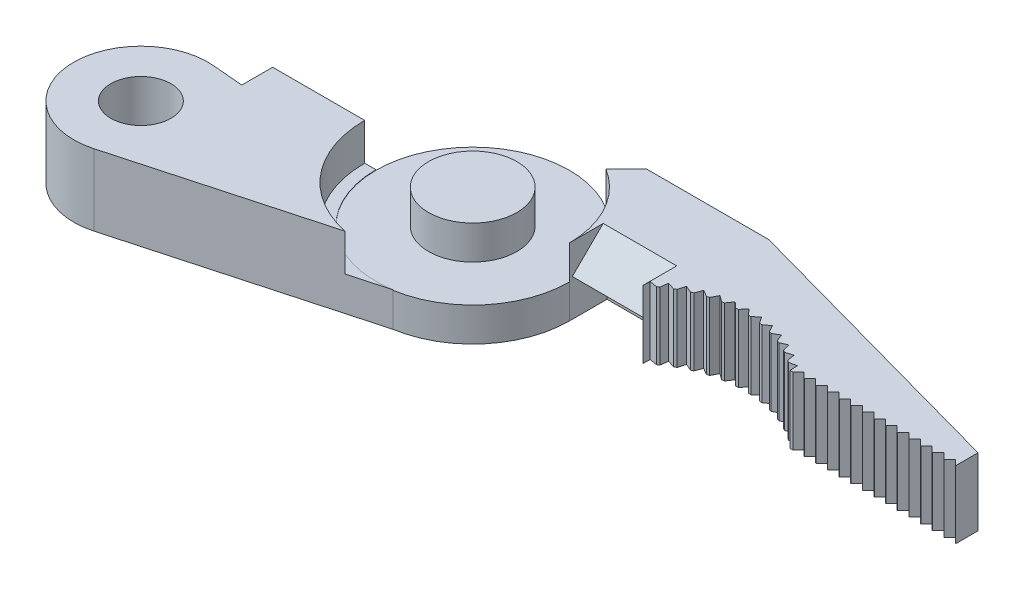
from build123d import *

# Parameters (mm, degrees)
SKETCH1_R                        = 6.5405
SKETCH1_R_2                      = 2.9845
BOSS_EXTRUDE1_DEPTH              = 4.826
SKETCH2_R                        = 2.032
BOSS_EXTRUDE2_DEPTH              = 4.826
F_42_0_0935_DIAMETER_HOLE1_D     = 2.3749
F_42_0_0935_DIAMETER_HOLE1_DEPTH = 2.032
F_42_0_0935_DIAMETER_HOLE1_TIP   = 0.713491942
BOSS_EXTRUDE3_DEPTH              = 4.826
CUT_EXTRUDE1_DEPTH               = 2.50825
CUT_EXTRUDE2_DEPTH               = 5.826
LPATTERN1_COUNT                  = 14
LPATTERN1_PITCH                  = 0.7874
CUT_EXTRUDE3_DEPTH               = 5.826
CIRPATTERN1_COUNT                = 13
CIRPATTERN1_ANGLE                = 76.5
SKETCH13_W                       = 4.971607039
SKETCH13_H                       = 2.54
CUT_EXTRUDE5_DEPTH               = 2.50825
BOSS_EXTRUDE4_REACH              = 28.099
SKETCH15_W                       = 4.971607039
SKETCH15_H                       = 2.54
CUT_EXTRUDE6_DEPTH               = 2.50825
SKETCH16_R                       = 6.5405
CUT_EXTRUDE7_DEPTH               = 2.54
SKETCH18_R                       = 2.9845
BOSS_EXTRUDE5_DEPTH              = 4.572
CUT_EXTRUDE8_DEPTH               = 0.254
CUT_EXTRUDE9_REACH               = 34.057


with BuildPart() as part:
    # Sketch1 → Boss-Extrude1 (new body)
    with BuildSketch(Plane(origin=(0, 0, 0), x_dir=(1, 0, 0), z_dir=(0, 1, 0))):
        Circle(SKETCH1_R)
        Circle(SKETCH1_R_2, mode=Mode.SUBTRACT)
    extrude(amount=BOSS_EXTRUDE1_DEPTH)

    # Sketch2 → Boss-Extrude2 (add)
    with BuildSketch(Plane(origin=(0, 0, 0), x_dir=(1, 0, 0), z_dir=(0, 1, 0))):
        with BuildLine():
            Line((-6.5405, 0), (-13.5255, 0))
            Line((-13.5255, 0), (-13.5255, -2.088510966))
            Line((-13.5255, -2.088510966), (-15.606063552, -1.906485242))
            ThreePointArc((-15.606063552, -1.906485242), (-20.526278057, -6.842542927), (-14.798031619, -10.81247605))
            Line((-14.798031619, -10.81247605), (1.058408056, -6.454294124))
            ThreePointArc((1.058408056, -6.454294124), (-4.234124606, -4.985010438), (-6.5405, 0))
        make_face()
        with Locations((-16.002, -6.432059555)):
            Circle(SKETCH2_R, mode=Mode.SUBTRACT)
    extrude(amount=BOSS_EXTRUDE2_DEPTH)

    # #42 (0.0935) Diameter Hole1
    with Locations(Plane(origin=(0, 0, 0), x_dir=(-1, 0, 0), z_dir=(0, 0, -1))):
        with Locations((10.033, 2.413)):
            Hole(F_42_0_0935_DIAMETER_HOLE1_D / 2, depth=F_42_0_0935_DIAMETER_HOLE1_DEPTH)
            with Locations((0, 0, -(F_42_0_0935_DIAMETER_HOLE1_DEPTH + F_42_0_0935_DIAMETER_HOLE1_TIP / 2))):  # 118° drill point
                Cone(0, F_42_0_0935_DIAMETER_HOLE1_D / 2, F_42_0_0935_DIAMETER_HOLE1_TIP, mode=Mode.SUBTRACT)

    # Sketch8 → Boss-Extrude3 (add)
    with BuildSketch(Plane(origin=(0, 0, 0), x_dir=(1, 0, 0), z_dir=(0, 1, 0))):
        with BuildLine():
            Line((13.081, 6.9342), (32.639, 1.524))
            Line((32.639, 1.524), (32.639, 0))
            Line((32.639, 0), (21.463, 0))
            ThreePointArc((21.463, 0), (16.51, 1.829301337), (11.557, 0))
            Line((11.557, 0), (6.5405, 0))
            ThreePointArc((6.5405, 0), (5.709882431, 3.189887596), (3.429, 5.569569036))
            Line((3.429, 5.569569036), (4.793630964, 6.9342))
            Line((4.793630964, 6.9342), (13.081, 6.9342))
        make_face()
    extrude(amount=BOSS_EXTRUDE3_DEPTH)

    # Sketch9 → Cut-Extrude1 (cut)
    with BuildSketch(Plane(origin=(0, 4.826, 0), x_dir=(1, 0, 0), z_dir=(0, 1, 0))):
        with BuildLine():
            Line((-6.5405, 0), (-7.3025, 0))
            ThreePointArc((-7.3025, 0), (-5.662092509, -4.611639044), (-1.477860583, -7.151393874))
            Line((-1.477860583, -7.151393874), (1.058408056, -6.454294124))
            ThreePointArc((1.058408056, -6.454294124), (-4.234124606, -4.985010438), (-6.5405, 0))
        make_face()
    extrude(amount=-CUT_EXTRUDE1_DEPTH, mode=Mode.SUBTRACT)

    # Sketch10 → Cut-Extrude2 (cut, through all)
    with BuildSketch(Plane(origin=(0, 4.826, 0), x_dir=(1, 0, 0), z_dir=(0, 1, 0))):
        Polygon((32.639, 0), (32.258, 0.381), (31.877, 0), align=None)
    cut_extrude2 = extrude(amount=-CUT_EXTRUDE2_DEPTH, mode=Mode.SUBTRACT)

    # LPattern1: Cut-Extrude2 ×14
    with Locations(*[(-i * LPATTERN1_PITCH, 0, 0) for i in range(1, LPATTERN1_COUNT)]):
        add(cut_extrude2, mode=Mode.SUBTRACT)

    # Sketch11 → Cut-Extrude3 (cut, through all)
    with BuildSketch(Plane(origin=(0, 4.826, 0), x_dir=(1, 0, 0), z_dir=(0, 1, 0))):
        with BuildLine():
            Line((21.463, 0), (21.438001029, 0.512539145))
            Line((21.438001029, 0.512539145), (20.934572554, 0.413135452))
            ThreePointArc((20.934572554, 0.413135452), (21.203334313, 0.212384964), (21.463, 0))
        make_face()
    cut_extrude3 = extrude(amount=-CUT_EXTRUDE3_DEPTH, mode=Mode.SUBTRACT)

    # CirPattern1: Cut-Extrude3 ×13 about axis
    cirpattern1_axis = Axis((16.51, 0, 5.790698663), (0, 1, 0))
    for i in range(1, CIRPATTERN1_COUNT):
        add(cut_extrude3.rotate(cirpattern1_axis, i * CIRPATTERN1_ANGLE / (CIRPATTERN1_COUNT - 1)), mode=Mode.SUBTRACT)

    # Sketch13 → Cut-Extrude5 (cut)
    with BuildSketch(Plane(origin=(0, 4.826, 0), x_dir=(1, 0, 0), z_dir=(0, 1, 0))):
        with Locations((9.02630352, 1.27)):
            Rectangle(SKETCH13_W, SKETCH13_H)
    extrude(amount=-CUT_EXTRUDE5_DEPTH, mode=Mode.SUBTRACT)

    # Sketch14 → Boss-Extrude4 (add, up to next)
    with BuildSketch(Plane(origin=(6.5405, 0, 0), x_dir=(0, 0, -1), z_dir=(1, 0, 0)), mode=Mode.PRIVATE) as boss_extrude4_sk1:
        Polygon((0, 2.31775), (2.54, 4.826), (2.54, 2.31775), align=None)
    boss_extrude4_tool1 = extrude(boss_extrude4_sk1.sketch, amount=BOSS_EXTRUDE4_REACH, mode=Mode.PRIVATE) - part.part
    add(boss_extrude4_tool1.solids().sort_by_distance((6.5405, 3.153833, -1.693333))[0])

    # Sketch15 → Cut-Extrude6 (cut)
    with BuildSketch(Plane.XZ):
        with Locations((9.02630352, -1.27)):
            Rectangle(SKETCH15_W, SKETCH15_H)
    extrude(amount=-CUT_EXTRUDE6_DEPTH, mode=Mode.SUBTRACT)

    # Sketch16 → Cut-Extrude7 (cut)
    with BuildSketch(Plane(origin=(0, 4.826, 0), x_dir=(1, 0, 0), z_dir=(0, 1, 0))):
        Circle(SKETCH16_R)
    extrude(amount=-CUT_EXTRUDE7_DEPTH, mode=Mode.SUBTRACT)

    # Sketch18 → Boss-Extrude5 (add)
    with BuildSketch(Plane(origin=(0, 0, 0), x_dir=(1, 0, 0), z_dir=(0, 1, 0))):
        Circle(SKETCH18_R)
    extrude(amount=BOSS_EXTRUDE5_DEPTH)

    # Sketch19 → Cut-Extrude8 (cut)
    with BuildSketch(Plane(origin=(0, 4.826, 0), x_dir=(1, 0, 0), z_dir=(0, 1, 0))):
        with BuildLine():
            Line((6.5405, 0), (6.5405, 2.54))
            Line((6.5405, 2.54), (11.512107039, 2.54))
            Line((11.512107039, 2.54), (11.512107039, 0))
            Line((11.512107039, 0), (11.531340148, 0.472602949))
            Line((11.531340148, 0.472602949), (12.03555369, 0.377261309))
            ThreePointArc((12.03555369, 0.377261309), (12.10743347, 0.428771407), (12.179906178, 0.479443879))
            Line((12.179906178, 0.479443879), (12.257573507, 0.986680619))
            Line((12.257573507, 0.986680619), (12.748082937, 0.835943022))
            ThreePointArc((12.748082937, 0.835943022), (12.825237685, 0.879153411), (12.90288869, 0.921465519))
            Line((12.90288869, 0.921465519), (13.036396947, 1.416941925))
            Line((13.036396947, 1.416941925), (13.507136098, 1.212672553))
            ThreePointArc((13.507136098, 1.212672553), (13.588611636, 1.247048848), (13.67048062, 1.280477314))
            Line((13.67048062, 1.280477314), (13.8581787, 1.758065792))
            Line((13.8581787, 1.758065792), (14.303325905, 1.502790861))
            ThreePointArc((14.303325905, 1.502790861), (14.388114618, 1.527907928), (14.473189102, 1.55203934))
            Line((14.473189102, 1.55203934), (14.712755728, 2.005833517))
            Line((14.712755728, 2.005833517), (15.126805817, 1.702710031))
            ThreePointArc((15.126805817, 1.702710031), (15.213859118, 1.718257244), (15.301086979, 1.732793167))
            Line((15.301086979, 1.732793167), (15.589559413, 2.157180937))
            Line((15.589559413, 2.157180937), (15.967391797, 1.809957647))
            ThreePointArc((15.967391797, 1.809957647), (16.05563309, 1.815742734), (16.143935576, 1.8205034))
            Line((16.143935576, 1.8205034), (16.477746256, 2.210236326))
            Line((16.477746256, 2.210236326), (16.814688254, 1.82320737))
            ThreePointArc((16.814688254, 1.82320737), (16.903026252, 1.819158785), (16.991311318, 1.81408532))
            Line((16.991311318, 1.81408532), (17.366331983, 2.164343546))
            Line((17.366331983, 2.164343546), (17.658216609, 1.742295339))
            ThreePointArc((17.658216609, 1.742295339), (17.745558829, 1.728463151), (17.832734648, 1.713618299))
            Line((17.832734648, 1.713618299), (18.244327388, 2.020070154))
            Line((18.244327388, 2.020070154), (18.487544881, 1.568222199))
            ThreePointArc((18.487544881, 1.568222199), (18.572811157, 1.544777473), (18.657799617, 1.52034482))
            Line((18.657799617, 1.52034482), (19.100874234, 1.779200392))
            Line((19.100874234, 1.779200392), (19.292416706, 1.303140726))
            ThreePointArc((19.292416706, 1.303140726), (19.374552542, 1.270373405), (19.456302586, 1.236655112))
            Line((19.456302586, 1.236655112), (19.925379542, 1.444713114))
            Line((19.925379542, 1.444713114), (20.062878172, 0.950329204))
            ThreePointArc((20.062878172, 0.950329204), (20.140867788, 0.908644522), (20.218368406, 0.866057587))
            Line((20.218368406, 0.866057587), (20.707646593, 1.02074495))
            Line((20.707646593, 1.02074495), (20.789400924, 0.514150878))
            ThreePointArc((20.789400924, 0.514150878), (20.862279817, 0.464064354), (20.934572554, 0.413135452))
            Line((20.934572554, 0.413135452), (21.438001029, 0.512539145))
            Line((21.438001029, 0.512539145), (21.463, 0))
            Line((21.463, 0), (21.6408, 0))
            Line((21.6408, 0), (22.0218, 0.381))
            Line((22.0218, 0.381), (22.4028, 0))
            Line((22.4028, 0), (22.4282, 0))
            Line((22.4282, 0), (22.8092, 0.381))
            Line((22.8092, 0.381), (23.1902, 0))
            Line((23.1902, 0), (23.2156, 0))
            Line((23.2156, 0), (23.5966, 0.381))
            Line((23.5966, 0.381), (23.9776, 0))
            Line((23.9776, 0), (24.003, 0))
            Line((24.003, 0), (24.384, 0.381))
            Line((24.384, 0.381), (24.765, 0))
            Line((24.765, 0), (24.7904, 0))
            Line((24.7904, 0), (25.1714, 0.381))
            Line((25.1714, 0.381), (25.5524, 0))
            Line((25.5524, 0), (25.5778, 0))
            Line((25.5778, 0), (25.9588, 0.381))
            Line((25.9588, 0.381), (26.3398, 0))
            Line((26.3398, 0), (26.3652, 0))
            Line((26.3652, 0), (26.7462, 0.381))
            Line((26.7462, 0.381), (27.1272, 0))
            Line((27.1272, 0), (27.1526, 0))
            Line((27.1526, 0), (27.5336, 0.381))
            Line((27.5336, 0.381), (27.9146, 0))
            Line((27.9146, 0), (27.94, 0))
            Line((27.94, 0), (28.321, 0.381))
            Line((28.321, 0.381), (28.702, 0))
            Line((28.702, 0), (28.7274, 0))
            Line((28.7274, 0), (29.1084, 0.381))
            Line((29.1084, 0.381), (29.4894, 0))
            Line((29.4894, 0), (29.5148, 0))
            Line((29.5148, 0), (29.8958, 0.381))
            Line((29.8958, 0.381), (30.2768, 0))
            Line((30.2768, 0), (30.3022, 0))
            Line((30.3022, 0), (30.6832, 0.381))
            Line((30.6832, 0.381), (31.0642, 0))
            Line((31.0642, 0), (31.0896, 0))
            Line((31.0896, 0), (31.4706, 0.381))
            Line((31.4706, 0.381), (31.8516, 0))
            Line((31.8516, 0), (31.877, 0))
            Line((31.877, 0), (32.258, 0.381))
            Line((32.258, 0.381), (32.639, 0))
            Line((32.639, 0), (32.639, 1.524))
            Line((32.639, 1.524), (13.081, 6.9342))
            Line((13.081, 6.9342), (4.793630964, 6.9342))
            Line((4.793630964, 6.9342), (3.429, 5.569569036))
            ThreePointArc((3.429, 5.569569036), (5.709882431, 3.189887596), (6.5405, 0))
        make_face()
    extrude(amount=-CUT_EXTRUDE8_DEPTH, mode=Mode.SUBTRACT)

    # Sketch20 → Cut-Extrude9 (cut, up to next)
    with BuildSketch(Plane(origin=(11.512107039, 0, 0), x_dir=(0, 0, -1), z_dir=(1, 0, 0)), mode=Mode.PRIVATE) as cut_extrude9_sk1:
        Polygon((2.54, 4.826), (2.28278481, 4.572), (2.54, 4.572), align=None)
    cut_extrude9_tool1 = extrude(cut_extrude9_sk1.sketch, amount=-CUT_EXTRUDE9_REACH, mode=Mode.PRIVATE) & part.part
    add(cut_extrude9_tool1.solids().sort_by_distance((11.512107, 4.656667, -2.454262))[0], mode=Mode.SUBTRACT)


solid = part.part
